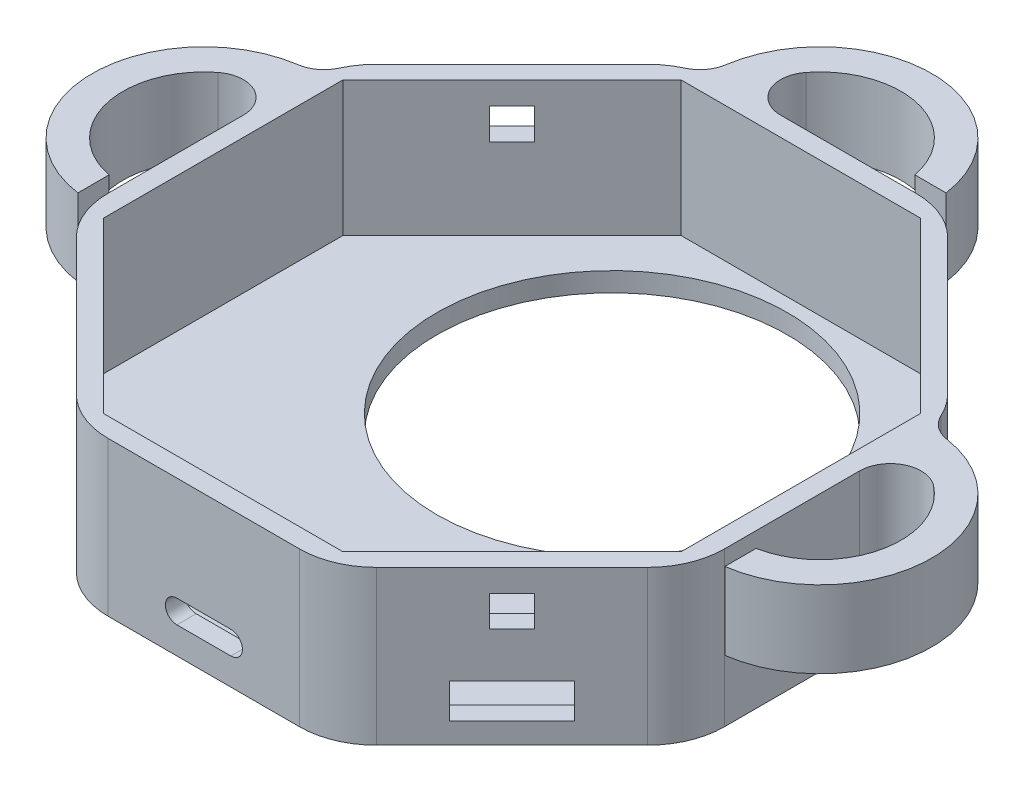
from build123d import *

# Parameters (mm, degrees)
BOSS_EXTRUDE1_DEPTH = 20
SKETCH5_W           = 4
SKETCH5_H           = 10
SKETCH16_W          = 2
SKETCH16_H          = 4.5
CUT_EXTRUDE9_DEPTH  = 10
SKETCH19_W          = 4
SKETCH19_H          = 10
CUT_EXTRUDE4_DEPTH  = 17.5
CUT_EXTRUDE5_DEPTH  = 2.5
SKETCH15_W          = 11.5
SKETCH15_H          = 4.5
CUT_EXTRUDE8_DEPTH  = 2.5
SKETCH17_W          = 14
SKETCH17_H          = 3
CUT_EXTRUDE10_DEPTH = 2.5
SKETCH21_W          = 4.5
SKETCH21_H          = 2
CUT_EXTRUDE11_DEPTH = 10
SKETCH22_R          = 2
CUT_EXTRUDE12_DEPTH = 2.5
FILLET1_R           = 10
FILLET2_R           = 4
SKETCH24_W          = 4.1
SKETCH24_H          = 4
CUT_EXTRUDE14_DEPTH = 77.5
SKETCH28_W          = 4.1
SKETCH28_H          = 4
CUT_EXTRUDE15_DEPTH = 77.5
SKETCH23_R          = 22.75
CUT_EXTRUDE13_DEPTH = 2.5


with BuildPart() as part:
    # Sketch1 → Boss-Extrude1 (new body)
    with BuildSketch(Plane(origin=(0, 0, 0), x_dir=(1, 0, 0), z_dir=(0, 1, 0))):
        Polygon((16.568542495, 40), (-16.568542495, 40), (-40, 16.568542495), (-40, -16.568542495), (-16.568542495, -40), (16.568542495, -40), (40, -16.568542495), (40, 16.568542495), align=None)
    extrude(amount=BOSS_EXTRUDE1_DEPTH)

    # Sweep9: sweep along a path in Sketch7
    with BuildLine(Plane(origin=(0, 15, 0), x_dir=(1, 0, 0), z_dir=(0, 1, 0))) as sweep9_path:
        ThreePointArc((40, -10.5), (50.5, 0), (40, 10.5))
    # Sketch5 → Sweep9 (sweep)
    with BuildSketch(Plane(origin=(40, 0, 0), x_dir=(0, 0, -1), z_dir=(1, 0, 0))):
        with Locations((-12.5, 15)):
            Rectangle(SKETCH5_W, SKETCH5_H)
        with Locations((12.5, 15)):
            Rectangle(SKETCH5_W, SKETCH5_H)
    sweep9 = sweep(path=sweep9_path.line)

    # Sketch16 → Cut-Extrude9 (cut)
    with BuildSketch(Plane(origin=(0, 20, 0), x_dir=(1, 0, 0), z_dir=(0, 1, 0))):
        with Locations((41, -12.25)):
            Rectangle(SKETCH16_W, SKETCH16_H)
    cut_extrude9 = extrude(amount=-CUT_EXTRUDE9_DEPTH, mode=Mode.SUBTRACT)

    # Mirror1: Sweep9, Cut-Extrude9 across plane
    add(sweep9.mirror(Plane(origin=(0, 0, 0), x_dir=(0, 0, 1), z_dir=(1, 0, 0))))
    add(cut_extrude9.mirror(Plane(origin=(0, 0, 0), x_dir=(0, 0, 1), z_dir=(1, 0, 0))), mode=Mode.SUBTRACT)

    # Sweep10: sweep along a path in Sketch20
    with BuildLine(Plane(origin=(0, 15, 0), x_dir=(1, 0, 0), z_dir=(0, 1, 0))) as sweep10_path:
        ThreePointArc((10.5, 40), (0, 50.5), (-10.5, 40))
    # Sketch19 → Sweep10 (sweep)
    with BuildSketch(Plane(origin=(0, 0, -40), x_dir=(-1, 0, 0), z_dir=(0, 0, -1))):
        with Locations((-12.5, 15)):
            Rectangle(SKETCH19_W, SKETCH19_H)
        with Locations((12.5, 15)):
            Rectangle(SKETCH19_W, SKETCH19_H)
    sweep(path=sweep10_path.line)

    # Sketch6 → Cut-Extrude4 (cut)
    with BuildSketch(Plane(origin=(0, 20, 0), x_dir=(1, 0, 0), z_dir=(0, 1, 0))):
        Polygon((-15.533008589, -37.5), (15.533008589, -37.5), (37.5, -15.533008589), (37.5, 15.533008589), (15.533008589, 37.5), (-15.533008589, 37.5), (-37.5, 15.533008589), (-37.5, -15.533008589), align=None)
    extrude(amount=-CUT_EXTRUDE4_DEPTH, mode=Mode.SUBTRACT)

    # Sketch3 → Cut-Extrude5 (cut)
    with BuildSketch(Plane.XY.offset(40)):
        with BuildLine():
            Line((-3.5, 6.5), (3.5, 6.5))
            ThreePointArc((3.5, 6.5), (5, 5), (3.5, 3.5))
            Line((3.5, 3.5), (-3.5, 3.5))
            ThreePointArc((-3.5, 3.5), (-5, 5), (-3.5, 6.5))
        make_face()
    extrude(amount=-CUT_EXTRUDE5_DEPTH, mode=Mode.SUBTRACT)

    # Sketch15 → Cut-Extrude8 (cut)
    with BuildSketch(Plane(origin=(28.284271247, 0, 28.284271247), x_dir=(0.707106781, 0, -0.707106781), z_dir=(0.707106781, 0, 0.707106781))):
        with Locations((0, 5)):
            Rectangle(SKETCH15_W, SKETCH15_H)
    extrude(amount=-CUT_EXTRUDE8_DEPTH, mode=Mode.SUBTRACT)

    # Sketch17 → Cut-Extrude10 (cut)
    with BuildSketch(Plane(origin=(-28.284271247, 0, 28.284271247), x_dir=(0.707106781, 0, 0.707106781), z_dir=(-0.707106781, 0, 0.707106781))):
        with Locations((0, 5)):
            Rectangle(SKETCH17_W, SKETCH17_H)
    extrude(amount=-CUT_EXTRUDE10_DEPTH, mode=Mode.SUBTRACT)

    # Sketch21 → Cut-Extrude11 (cut)
    with BuildSketch(Plane(origin=(0, 20, 0), x_dir=(1, 0, 0), z_dir=(0, 1, 0))):
        with Locations((12.25, 41)):
            Rectangle(SKETCH21_W, SKETCH21_H)
    extrude(amount=-CUT_EXTRUDE11_DEPTH, mode=Mode.SUBTRACT)

    # Sketch22 → Cut-Extrude12 (cut)
    with BuildSketch(Plane(origin=(28.284271247, 0, -28.284271247), x_dir=(-0.707106781, 0, -0.707106781), z_dir=(0.707106781, 0, -0.707106781))):
        with Locations((0, 10)):
            Circle(SKETCH22_R)
    extrude(amount=-CUT_EXTRUDE12_DEPTH, mode=Mode.SUBTRACT)

    # Fillet1
    fillet1_edges = [part.edges().sort_by_distance(p)[0] for p in [
        (-40, 10, -16.568542495),
        (-16.568542495, 10, -40),
        (16.568542495, 10, -40),
        (40, 10, -16.568542495),
        (-40, 10, 16.568542495),
        (40, 10, 16.568542495),
        (16.568542495, 10, 40),
        (-16.568542495, 10, 40),
    ]]
    fillet(fillet1_edges, radius=FILLET1_R)

    # Fillet2
    fillet2_edges = [part.edges().sort_by_distance(p)[0] for p in [
        (-10.5, 15, -40),
        (40, 15, -10.5),
        (-39.782992577, 15, -14.498376039),
        (-14.498376039, 15, -39.782992577),
        (39.782992577, 15, -14.498376039),
        (-40, 15, -10.5),
    ]]
    fillet(fillet2_edges, radius=FILLET2_R)

    # Sketch24 → Cut-Extrude14 (cut)
    with BuildSketch(Plane(origin=(-28.284271247, 0, 28.284271247), x_dir=(0.707106781, 0, 0.707106781), z_dir=(-0.707106781, 0, 0.707106781))):
        with Locations((0, 15.05)):
            Rectangle(SKETCH24_W, SKETCH24_H)
    cut_extrude14 = extrude(amount=-CUT_EXTRUDE14_DEPTH, mode=Mode.SUBTRACT)

    # Mirror2: Cut-Extrude14 across plane
    add(cut_extrude14.mirror(Plane(origin=(0, 0, 0), x_dir=(0.707106781, 0, 0.707106781), z_dir=(-0.707106781, 0, 0.707106781))), mode=Mode.SUBTRACT)

    # Sketch28 → Cut-Extrude15 (cut)
    with BuildSketch(Plane(origin=(28.284271247, 0, 28.284271247), x_dir=(0.707106781, 0, -0.707106781), z_dir=(0.707106781, 0, 0.707106781))):
        with Locations((0, 15.05)):
            Rectangle(SKETCH28_W, SKETCH28_H)
    cut_extrude15 = extrude(amount=-CUT_EXTRUDE15_DEPTH, mode=Mode.SUBTRACT)

    # Mirror3: Cut-Extrude15 across plane
    add(cut_extrude15.mirror(Plane(origin=(0, 0, 0), x_dir=(-0.707106781, 0, 0.707106781), z_dir=(0.707106781, 0, 0.707106781))), mode=Mode.SUBTRACT)

    # Sketch23 → Cut-Extrude13 (cut)
    with BuildSketch(Plane(origin=(0, 2.5, 0), x_dir=(1, 0, 0), z_dir=(0, 1, 0))):
        with Locations((0, 13)):
            Circle(SKETCH23_R)
    extrude(amount=-CUT_EXTRUDE13_DEPTH, mode=Mode.SUBTRACT)


solid = part.part
